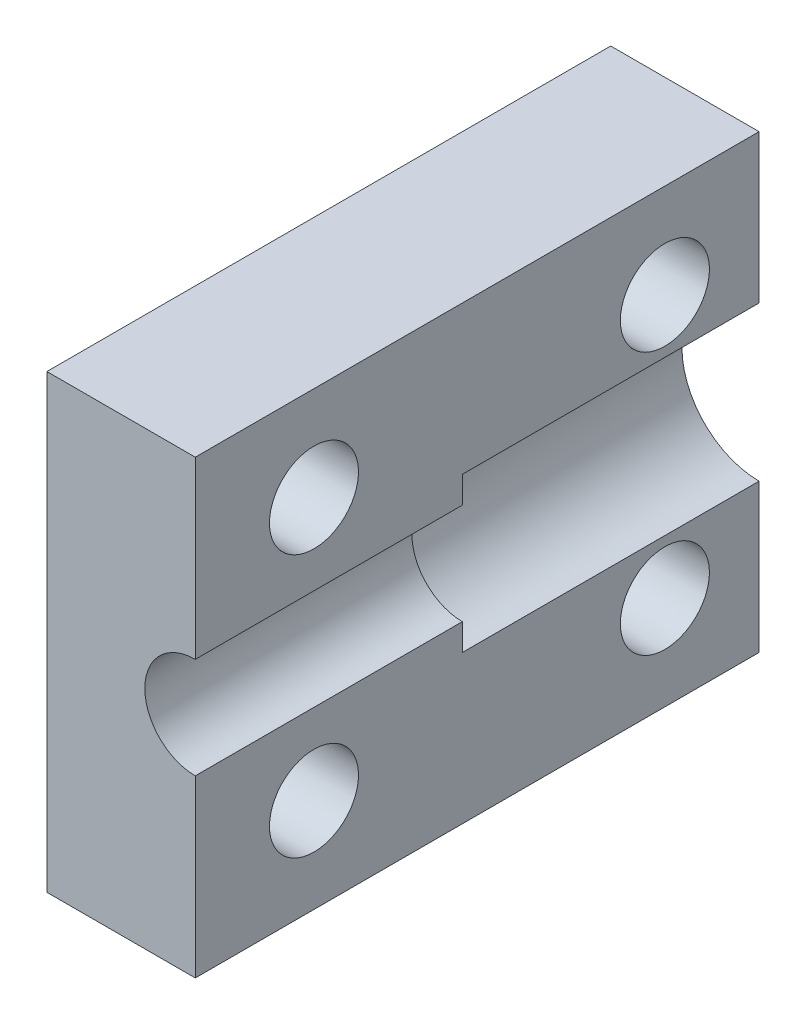
from build123d import *

# Parameters (mm, degrees)
EXTRUDE1_DEPTH = 10
EXTRUDE2_DEPTH = 9
SKETCH4_R      = 1.5
EXTRUDE3_DEPTH = 6


with BuildPart() as part:
    # Sketch1 → Extrude1 (new body)
    with BuildSketch(Plane.XY):
        with BuildLine():
            Line((0, 2.6), (0, 7.6))
            Line((0, 7.6), (-5, 7.6))
            Line((-5, 7.6), (-5, -7.6))
            Line((-5, -7.6), (0, -7.6))
            Line((0, -7.6), (0, -2.6))
            ThreePointArc((0, -2.6), (-2.6, 0), (0, 2.6))
        make_face()
    extrude(amount=EXTRUDE1_DEPTH)

    # Sketch2 → Extrude2 (add)
    with BuildSketch(Plane.XY.offset(10)):
        with BuildLine():
            Line((0, 1.7), (0, 7.6))
            Line((0, 7.6), (-5, 7.6))
            Line((-5, 7.6), (-5, -7.6))
            Line((-5, -7.6), (0, -7.6))
            Line((0, -7.6), (0, -1.7))
            ThreePointArc((0, -1.7), (-1.7, 0), (0, 1.7))
        make_face()
    extrude(amount=EXTRUDE2_DEPTH)

    # Sketch4 → Extrude3 (cut, through all)
    with BuildSketch(Plane.ZY.offset(5)):
        with Locations((3.175, 4.425)):
            Circle(SKETCH4_R)
        with Locations((15, 4.425)):
            Circle(SKETCH4_R)
        with Locations((15, -4.425)):
            Circle(SKETCH4_R)
        with Locations((3.175, -4.425)):
            Circle(SKETCH4_R)
    extrude(amount=-EXTRUDE3_DEPTH, mode=Mode.SUBTRACT)


solid = part.part
